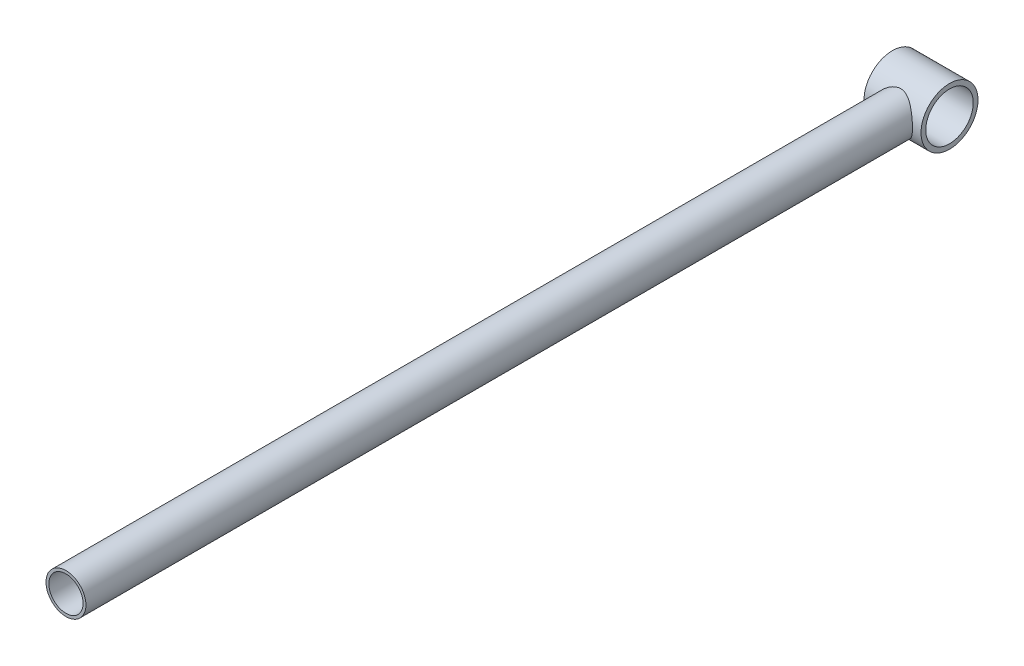
from build123d import *

# Parameters (mm, degrees)
SKETCH_1_R          = 21
EXTRUDE_1_DEPTH     = 900
SKETCH_2_R          = 18
CUT_EXTRUDE_1_DEPTH = 901
SKETCH_4_R          = 30
EXTRUDE_2_DEPTH     = 30
SKETCH_5_R          = 25
CUT_EXTRUDE_2_DEPTH = 61.0000001


with BuildPart() as part:
    # Эскиз1 → Бобышка-Вытянуть1 (new body)
    with BuildSketch(Plane.XY):
        Circle(SKETCH_1_R)
    extrude(amount=EXTRUDE_1_DEPTH)

    # Эскиз2 → Вырез-Вытянуть1 (cut, through all)
    with BuildSketch(Plane(origin=(0, 0, 0), x_dir=(-1, 0, 0), z_dir=(0, 0, -1))):
        Circle(SKETCH_2_R)
    extrude(amount=-CUT_EXTRUDE_1_DEPTH, mode=Mode.SUBTRACT)

    # Эскиз4 → Бобышка-Вытянуть2 (add, symmetric)
    with BuildSketch(Plane(origin=(0, 0, 0), x_dir=(0, 0, -1), z_dir=(1, 0, 0))):
        Circle(SKETCH_4_R)
    extrude(amount=EXTRUDE_2_DEPTH, both=True)

    # Эскиз5 → Вырез-Вытянуть2 (cut, through all)
    with BuildSketch(Plane(origin=(30, 0, 0), x_dir=(0, 0, -1), z_dir=(1, 0, 0))):
        Circle(SKETCH_5_R)
    extrude(amount=-CUT_EXTRUDE_2_DEPTH, mode=Mode.SUBTRACT)


solid = part.part
